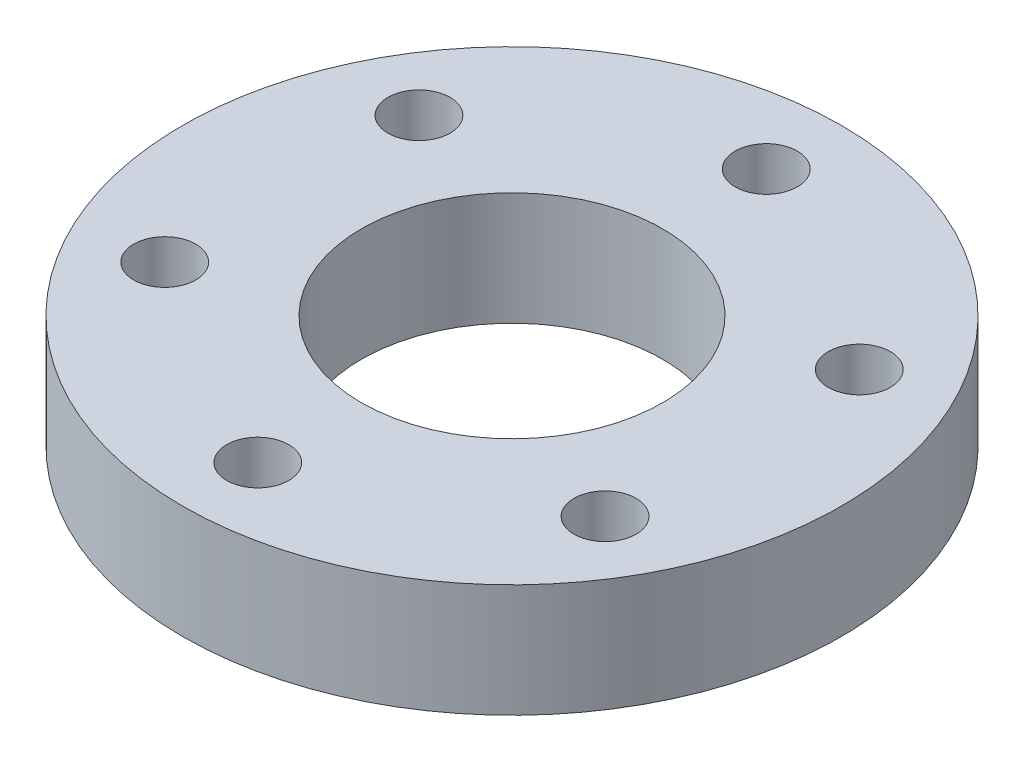
from build123d import *

# Parameters (mm, degrees)
SKETCH_1_R      = 17.5
SKETCH_1_R_2    = 8
SKETCH_1_R_3    = 1.65
EXTRUDE_1_DEPTH = 6


with BuildPart() as part:
    # 草图1 → 凸台-拉伸1 (new body)
    with BuildSketch(Plane(origin=(0, 0, 0), x_dir=(1, 0, 0), z_dir=(0, 1, 0))):
        Circle(SKETCH_1_R)
        Circle(SKETCH_1_R_2, mode=Mode.SUBTRACT)
        with Locations((0, 13.5)):
            Circle(SKETCH_1_R_3, mode=Mode.SUBTRACT)
        with Locations((11.691342951, 6.75)):
            Circle(SKETCH_1_R_3, mode=Mode.SUBTRACT)
        with Locations((11.691342951, -6.75)):
            Circle(SKETCH_1_R_3, mode=Mode.SUBTRACT)
        with Locations((0, -13.5)):
            Circle(SKETCH_1_R_3, mode=Mode.SUBTRACT)
        with Locations((-11.691342951, -6.75)):
            Circle(SKETCH_1_R_3, mode=Mode.SUBTRACT)
        with Locations((-11.691342951, 6.75)):
            Circle(SKETCH_1_R_3, mode=Mode.SUBTRACT)
    extrude(amount=EXTRUDE_1_DEPTH)


solid = part.part
